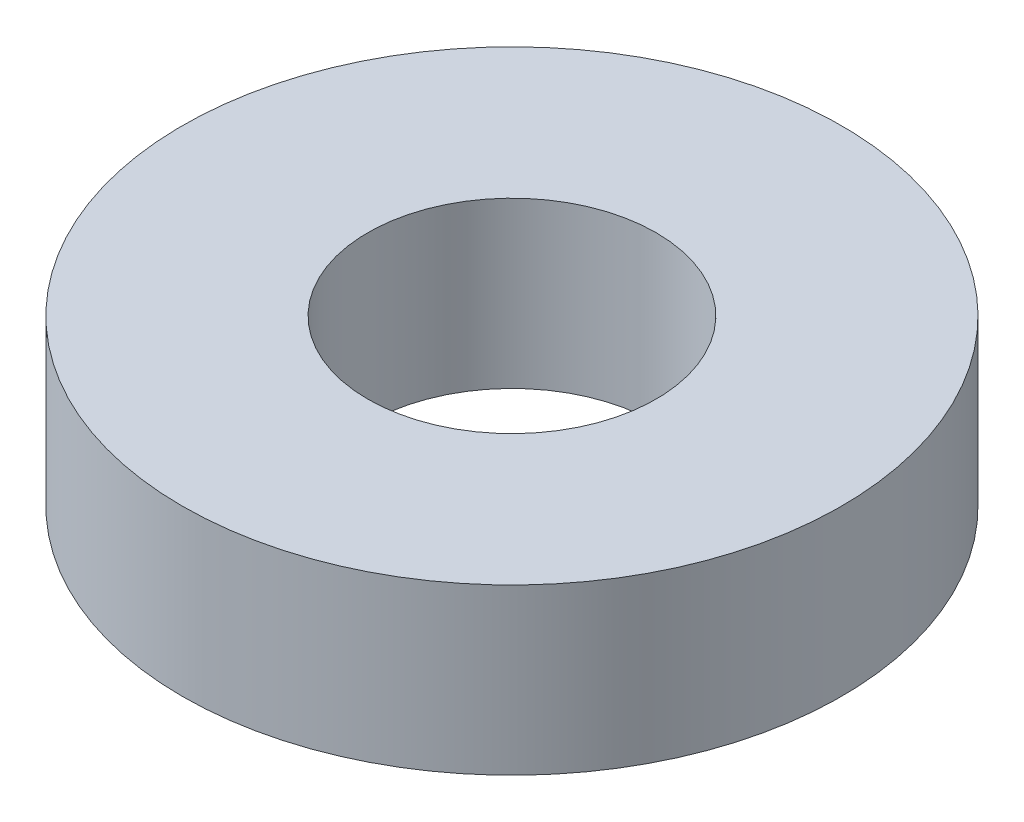
from build123d import *

# Parameters (mm, degrees)
SKETCH1_R           = 4
SKETCH1_R_2         = 1.75
BOSS_EXTRUDE1_DEPTH = 2


with BuildPart() as part:
    # Sketch1 → Boss-Extrude1 (new body)
    with BuildSketch(Plane(origin=(0, 0, 0), x_dir=(1, 0, 0), z_dir=(0, 1, 0))):
        Circle(SKETCH1_R)
        Circle(SKETCH1_R_2, mode=Mode.SUBTRACT)
    extrude(amount=BOSS_EXTRUDE1_DEPTH)


solid = part.part
